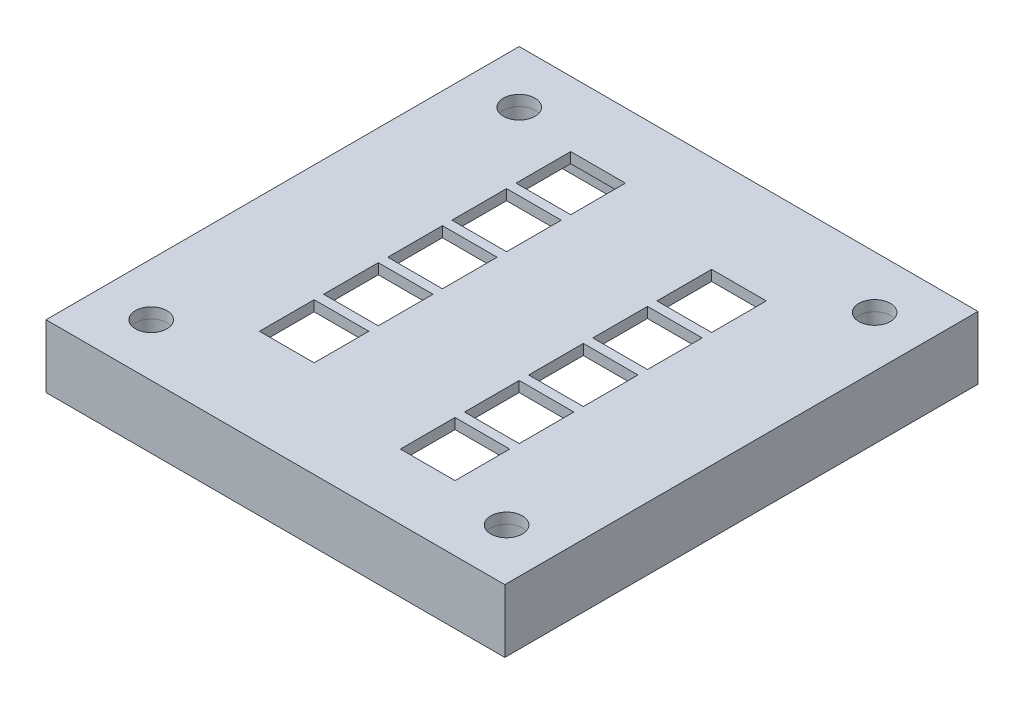
from build123d import *

# Parameters (mm, degrees)
SKETCH_1_W          = 43.6316
SKETCH_1_H          = 45
SKETCH_1_RX         = 1.5
SKETCH_1_RY         = 1.5
SKETCH_1_W_2        = 5.2
SKETCH_1_H_2        = 5.2
EXTRUDE_1_DEPTH     = 1
SKETCH_3_R          = 4
SKETCH_3_R_2        = 1.5
EXTRUDE_3_DEPTH     = 1.2
SKETCH_4_W          = 43.6316
SKETCH_4_H          = 45
SKETCH_4_W_2        = 39.6316
SKETCH_4_H_2        = 41
EXTRUDE_4_DEPTH     = 5
SKETCH_5_W          = 2
SKETCH_5_H          = 25
CUT_EXTRUDE_1_DEPTH = 5


with BuildPart() as part:
    # Эскиз1 → Бобышка-Вытянуть1 (new body)
    with BuildSketch(Plane(origin=(0, 0, 0), x_dir=(1, 0, 0), z_dir=(0, 1, 0))):
        with Locations((-0.355064662, -0.618327068)):
            Rectangle(SKETCH_1_W, SKETCH_1_H)
        with Locations(Location((-17.170864662, 16.881672932), (0, 0, 90))):
            Ellipse(SKETCH_1_RX, SKETCH_1_RY, mode=Mode.SUBTRACT)
        with Locations(Location((-17.170864662, -18.118327068), (0, 0, 90))):
            Ellipse(SKETCH_1_RX, SKETCH_1_RY, mode=Mode.SUBTRACT)
        with Locations(Location((16.629135338, 16.881672932), (0, 0, 90))):
            Ellipse(SKETCH_1_RX, SKETCH_1_RY, mode=Mode.SUBTRACT)
        with Locations(Location((16.629135338, -18.118327068), (0, 0, 90))):
            Ellipse(SKETCH_1_RX, SKETCH_1_RY, mode=Mode.SUBTRACT)
        with Locations((-8.470864662, 13.081672932)):
            Rectangle(SKETCH_1_W_2, SKETCH_1_H_2, mode=Mode.SUBTRACT)
        with Locations((-8.470864662, 6.981672932)):
            Rectangle(SKETCH_1_W_2, SKETCH_1_H_2, mode=Mode.SUBTRACT)
        with Locations((-8.470864662, 0.881672932)):
            Rectangle(SKETCH_1_W_2, SKETCH_1_H_2, mode=Mode.SUBTRACT)
        with Locations((-8.470864662, -5.218327068)):
            Rectangle(SKETCH_1_W_2, SKETCH_1_H_2, mode=Mode.SUBTRACT)
        with Locations((-8.470864662, -11.318627068)):
            Rectangle(SKETCH_1_W_2, SKETCH_1_H_2, mode=Mode.SUBTRACT)
        with Locations((7.929135338, 10.081372932)):
            Rectangle(SKETCH_1_W_2, SKETCH_1_H_2, mode=Mode.SUBTRACT)
        with Locations((7.929135338, 3.981372932)):
            Rectangle(SKETCH_1_W_2, SKETCH_1_H_2, mode=Mode.SUBTRACT)
        with Locations((7.929135338, -2.118627068)):
            Rectangle(SKETCH_1_W_2, SKETCH_1_H_2, mode=Mode.SUBTRACT)
        with Locations((7.929135338, -8.218627068)):
            Rectangle(SKETCH_1_W_2, SKETCH_1_H_2, mode=Mode.SUBTRACT)
        with Locations((7.929135338, -14.318627068)):
            Rectangle(SKETCH_1_W_2, SKETCH_1_H_2, mode=Mode.SUBTRACT)
    extrude(amount=EXTRUDE_1_DEPTH)

    # Эскиз3 → Бобышка-Вытянуть3 (add)
    with BuildSketch(Plane.XZ):
        with Locations((-17.170864662, 18.118327068)):
            Circle(SKETCH_3_R)
        with Locations((-17.170864662, 18.118327068)):
            Circle(SKETCH_3_R_2, mode=Mode.SUBTRACT)
        with Locations((16.629135338, 18.118327068)):
            Circle(SKETCH_3_R)
        with Locations((16.629135338, 18.118327068)):
            Circle(SKETCH_3_R_2, mode=Mode.SUBTRACT)
        with Locations((-17.170864662, -16.881672932)):
            Circle(SKETCH_3_R)
        with Locations((-17.170864662, -16.881672932)):
            Circle(SKETCH_3_R_2, mode=Mode.SUBTRACT)
        with Locations((16.629135338, -16.881672932)):
            Circle(SKETCH_3_R)
        with Locations((16.629135338, -16.881672932)):
            Circle(SKETCH_3_R_2, mode=Mode.SUBTRACT)
    extrude(amount=EXTRUDE_3_DEPTH)

    # Эскиз4 → Бобышка-Вытянуть4 (add)
    with BuildSketch(Plane.XZ):
        with Locations((-0.355064662, 0.618327068)):
            Rectangle(SKETCH_4_W, SKETCH_4_H)
        with Locations((-0.355064662, 0.618327068)):
            Rectangle(SKETCH_4_W_2, SKETCH_4_H_2, mode=Mode.SUBTRACT)
    extrude(amount=EXTRUDE_4_DEPTH)

    # Эскиз5 → Вырез-Вытянуть1 (cut)
    with BuildSketch(Plane.XZ.offset(5)):
        with Locations((-21.170864662, 0.618327068)):
            Rectangle(SKETCH_5_W, SKETCH_5_H)
    extrude(amount=-CUT_EXTRUDE_1_DEPTH, mode=Mode.SUBTRACT)


solid = part.part
